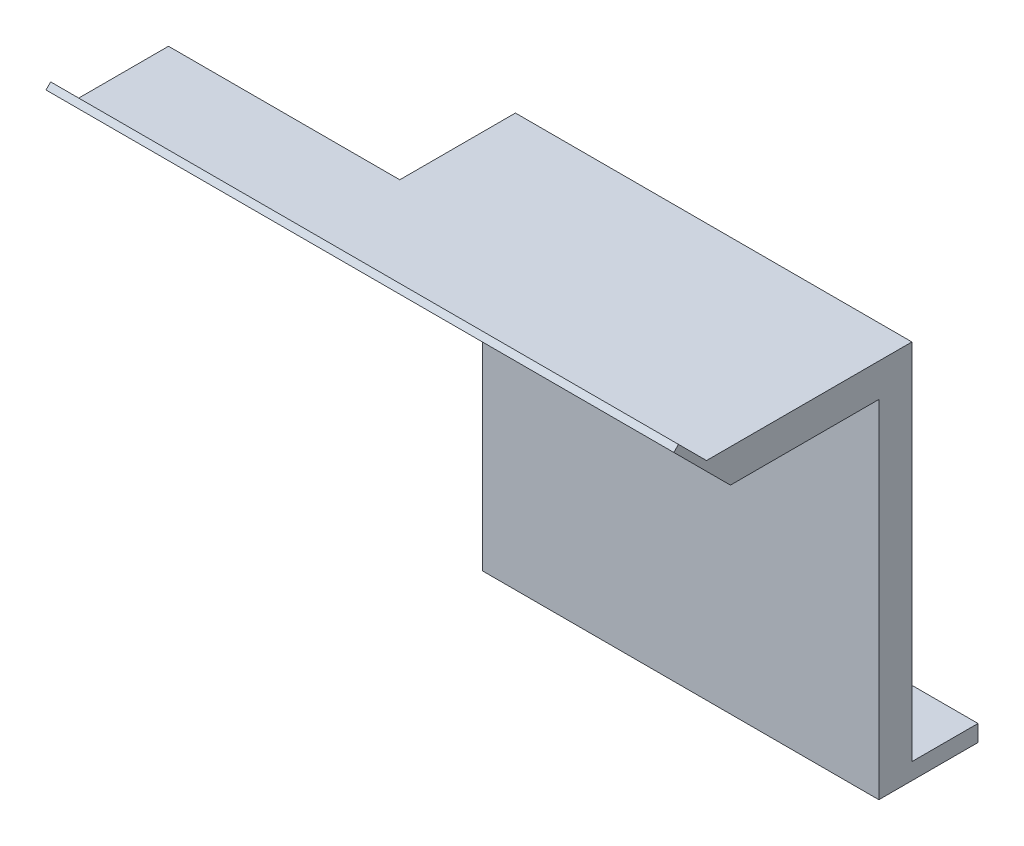
from build123d import *

# Parameters (mm, degrees)
SKETCH1_W                = 152.4
SKETCH1_H                = 38.1
BOSS_EXTRUDE1_DEPTH      = 6.35
SKETCH2_R                = 3.175
CUT_EXTRUDE1_DEPTH       = 7.35
SKETCH3_W                = 152.4
SKETCH3_H                = 12.7
BOSS_EXTRUDE2_DEPTH      = 139.7
SKETCH4_W                = 82.55
SKETCH4_H                = 12.793482267
BOSS_EXTRUDE3_DEPTH      = 88.9
BOSS_EXTRUDE3_DEPTH_BACK = 152.4
SKETCH5_W                = 88.9
SKETCH5_H                = 44.45
CUT_EXTRUDE2_DEPTH       = 152.4
CUT_EXTRUDE3_DEPTH       = 242.3
BOSS_EXTRUDE4_DEPTH      = 241.3


with BuildPart() as part:
    # Sketch1 → Boss-Extrude1 (new body)
    with BuildSketch(Plane(origin=(0, 0, 0), x_dir=(1, 0, 0), z_dir=(0, 1, 0))):
        with Locations((69.256115108, 12.928417266)):
            Rectangle(SKETCH1_W, SKETCH1_H)
    extrude(amount=BOSS_EXTRUDE1_DEPTH)

    # Sketch2 → Cut-Extrude1 (cut, through all)
    with BuildSketch(Plane(origin=(0, 6.35, 0), x_dir=(1, 0, 0), z_dir=(0, 1, 0))):
        with Locations((-0.593884892, 12.928417266)):
            Circle(SKETCH2_R)
        with Locations((24.806115108, 12.928417266)):
            Circle(SKETCH2_R)
        with Locations((50.206115108, 12.928417266)):
            Circle(SKETCH2_R)
        with Locations((75.606115108, 12.928417266)):
            Circle(SKETCH2_R)
        with Locations((101.006115108, 12.928417266)):
            Circle(SKETCH2_R)
        with Locations((126.406115108, 12.928417266)):
            Circle(SKETCH2_R)
    extrude(amount=-CUT_EXTRUDE1_DEPTH, mode=Mode.SUBTRACT)

    # Sketch3 → Boss-Extrude2 (add)
    with BuildSketch(Plane(origin=(0, 6.35, 0), x_dir=(1, 0, 0), z_dir=(0, 1, 0))):
        with Locations((69.256115108, 0.228417266)):
            Rectangle(SKETCH3_W, SKETCH3_H)
    extrude(amount=BOSS_EXTRUDE2_DEPTH)

    # Sketch4 → Boss-Extrude3 (add, two sides)
    with BuildSketch(Plane.ZY.offset(6.943884892)) as boss_extrude3_sk:
        with Locations((34.696582734, 139.653258867)):
            Rectangle(SKETCH4_W, SKETCH4_H)
    extrude(amount=BOSS_EXTRUDE3_DEPTH)
    extrude(boss_extrude3_sk.sketch, amount=-BOSS_EXTRUDE3_DEPTH_BACK)

    # Sketch5 → Cut-Extrude2 (cut)
    with BuildSketch(Plane(origin=(0, 146.05, 0), x_dir=(1, 0, 0), z_dir=(0, 1, 0))):
        with Locations((-51.393884892, -15.646582734)):
            Rectangle(SKETCH5_W, SKETCH5_H)
    extrude(amount=-CUT_EXTRUDE2_DEPTH, mode=Mode.SUBTRACT)

    # Sketch6 → Cut-Extrude3 (cut, through all)
    with BuildSketch(Plane.ZY.offset(95.843884892)):
        Polygon((75.971582734, 146.05), (63.178100467, 133.256517733), (75.971582734, 133.256517733), align=None)
    extrude(amount=-CUT_EXTRUDE3_DEPTH, mode=Mode.SUBTRACT)

    # Sketch7 → Boss-Extrude4 (add, through all)
    with BuildSketch(Plane.ZY.offset(95.843884892)):
        Polygon((84.951838855, 155.030256121), (83.155787631, 156.826307345), (65.195275389, 138.865795103), (66.991326613, 137.069743879), align=None)
    extrude(amount=-BOSS_EXTRUDE4_DEPTH)


solid = part.part
